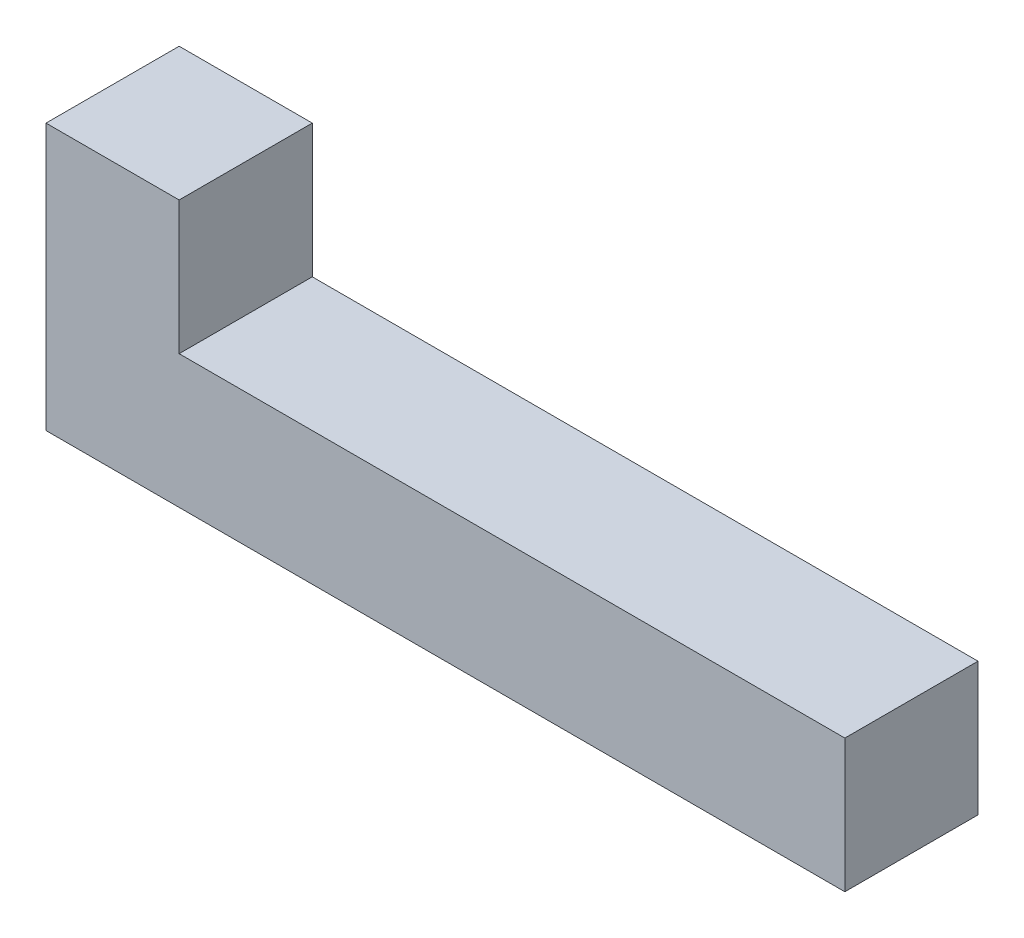
from build123d import *

# Parameters (mm, degrees)
ESQUISSE1_W        = 30
ESQUISSE1_H        = 5
ESQUISSE1_W_2      = 5
BOSS_EXTRU_1_DEPTH = 5


with BuildPart() as part:
    # Esquisse1 → Boss.-Extru.1 (new body)
    with BuildSketch(Plane.XY):
        with Locations((10.282439123, 3.085056057)):
            Rectangle(ESQUISSE1_W, ESQUISSE1_H)
        with Locations((-2.217560877, 8.085056057)):
            Rectangle(ESQUISSE1_W_2, ESQUISSE1_H)
    extrude(amount=BOSS_EXTRU_1_DEPTH)


solid = part.part
